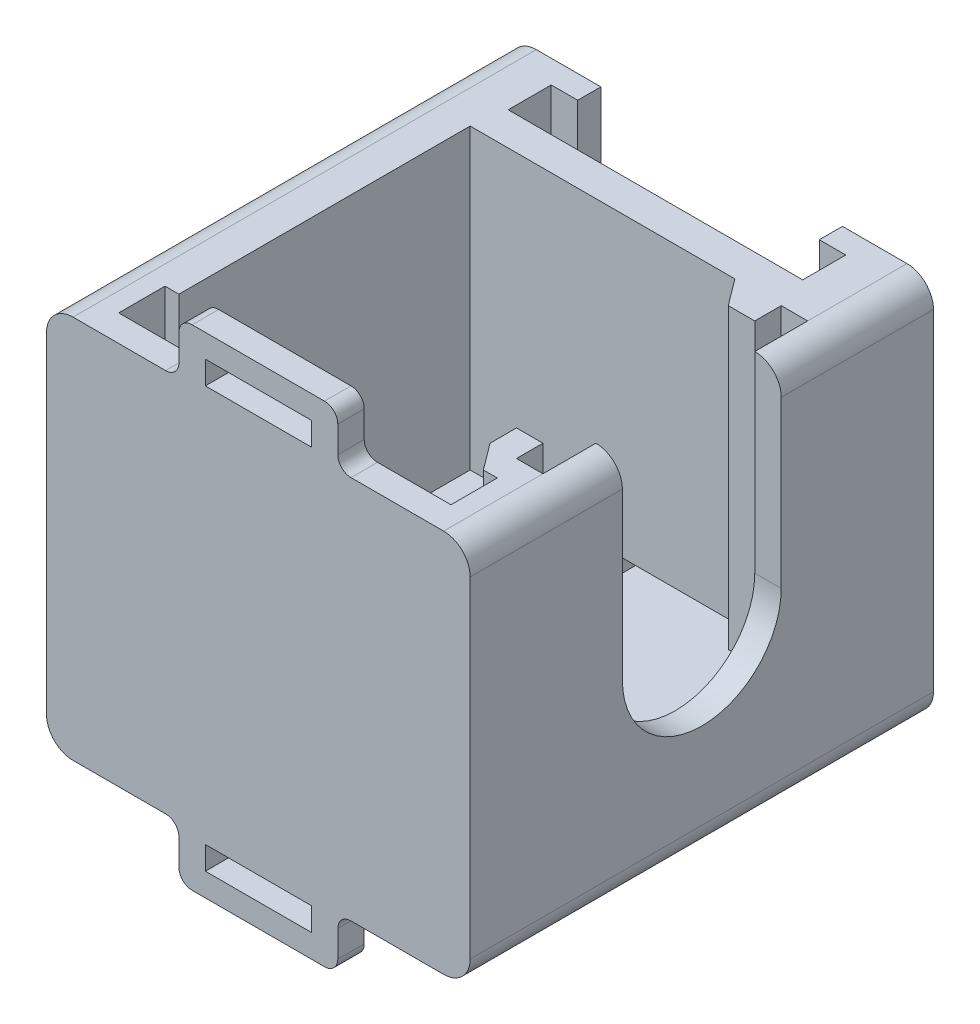
from build123d import *

# Parameters (mm, degrees)
SKETCH1_W                         = 32
SKETCH1_H                         = 29
BOSS_EXTRUDE1_DEPTH               = 35
FILLET1_R                         = 2
SLOT_FOR_COIL_DEPTH               = 1
SLOT_FOR_COIL_DEPTH_BACK          = 30
BOSS_EXTRUDE2_DEPTH               = 6.5
BOSS_EXTRUDE3_DEPTH               = 1.75
SKETCH5_W                         = 2
SKETCH5_H                         = 6.5
SLOT_TO_FEED_IN_WIRE_DEPTH        = 33
SLOT_FO_PCB_DEPTH                 = 22.5
SKETCH7_W                         = 2
SKETCH7_H                         = 33
BOSS_EXTRUDE4_DEPTH               = 2.5
FILLET2_R                         = 6
ROD_MOUNT_SLOT_REACH              = 34
SKETCH14_W                        = 2.5
SKETCH14_H                        = 20
SIDE_CAVITY_FOR_MOUNT_PLATE_DEPTH = 22.5
SKETCH16_W                        = 2
SKETCH16_H                        = 2
SIDE_STOPS_FOR_MOUNT_PLATE_DEPTH  = 22.5
BOSS_EXTRUDE6_DEPTH               = 22.5
SKETCH21_W                        = 12
SKETCH21_H                        = 2
BOSS_EXTRUDE7_DEPTH               = 4
SKETCH23_W                        = 8
SKETCH23_H                        = 1.75
CUT_EXTRUDE7_DEPTH                = 2
FILLET3_R                         = 1
CUT_EXTRUDE8_REACH                = 34
SKETCH26_R                        = 5.25


with BuildPart() as part:
    # Sketch1 → Boss-Extrude1 (new body)
    with BuildSketch(Plane.XY):
        Rectangle(SKETCH1_W, SKETCH1_H)
    extrude(amount=BOSS_EXTRUDE1_DEPTH)

    # Fillet1
    fillet1_edges = [part.edges().sort_by_distance(p)[0] for p in [
        (16, -14.5, 17.5),
        (-16, -14.5, 17.5),
        (-16, 14.5, 17.5),
        (16, 14.5, 17.5),
    ]]
    fillet(fillet1_edges, radius=FILLET1_R)

    # Sketch2 → Slot for Coil (cut, two sides)
    with BuildSketch(Plane.XZ.offset(14.5)) as slot_for_coil_sk:
        Polygon((-9.125, 0), (-9.125, 1.75), (-11.125, 1.75), (-11.125, 5), (11.125, 5), (11.125, 1.75), (9.125, 1.75), (9.125, 0), align=None)
    extrude(amount=SLOT_FOR_COIL_DEPTH, mode=Mode.SUBTRACT)
    extrude(slot_for_coil_sk.sketch, amount=-SLOT_FOR_COIL_DEPTH_BACK, mode=Mode.SUBTRACT)

    # Sketch3 → Boss-Extrude2 (add)
    with BuildSketch(Plane.XZ.offset(14.5)):
        Polygon((-9.125, 0), (-9.125, 1.75), (-11.125, 1.75), (-11.125, 5), (11.125, 5), (11.125, 1.75), (9.125, 1.75), (9.125, 0), align=None)
    extrude(amount=-BOSS_EXTRUDE2_DEPTH)

    # Sketch4 → Boss-Extrude3 (add)
    with BuildSketch(Plane(origin=(0, 0, 1.75), x_dir=(-1, 0, 0), z_dir=(0, 0, -1))):
        with BuildLine():
            Line((-9.125, 7.5), (-9.125, 6.5))
            ThreePointArc((-9.125, 6.5), (-8.875, 7), (-9.125, 7.5))
        make_face()
    boss_extrude3 = extrude(amount=BOSS_EXTRUDE3_DEPTH)

    # Mirror1: Boss-Extrude3 across plane
    add(boss_extrude3.mirror(Plane(origin=(0, 0, 0), x_dir=(0, 0, 1), z_dir=(1, 0, 0))))

    # Sketch5 → slot to feed in wire (cut)
    with BuildSketch(Plane(origin=(0, 0, 0), x_dir=(-1, 0, 0), z_dir=(0, 0, -1))):
        with Locations((0, -11.25)):
            Rectangle(SKETCH5_W, SKETCH5_H)
    extrude(amount=-SLOT_TO_FEED_IN_WIRE_DEPTH, mode=Mode.SUBTRACT)

    # Sketch6 → slot fo PCB (cut)
    with BuildSketch(Plane(origin=(0, 14.5, 0), x_dir=(1, 0, 0), z_dir=(0, 1, 0))):
        Polygon((11.5, -7.5), (-11.5, -7.5), (-11.5, -29.5), (-12.55, -29.5), (-12.55, -33), (12.55, -33), (12.55, -29.5), (11.5, -29.5), align=None)
    extrude(amount=-SLOT_FO_PCB_DEPTH, mode=Mode.SUBTRACT)

    # Sketch7 → Boss-Extrude4 (add)
    with BuildSketch(Plane.XZ.offset(14.5)):
        with Locations((0, 16.5)):
            Rectangle(SKETCH7_W, SKETCH7_H)
    extrude(amount=-BOSS_EXTRUDE4_DEPTH)

    # Fillet2
    fillet2_edges = [part.edges().sort_by_distance(p)[0] for p in [
        (0, -12, 33),
    ]]
    fillet(fillet2_edges, radius=FILLET2_R)

    # Sketch11 → Rod Mount Slot (cut, up to next)
    with BuildSketch(Plane(origin=(16, 0, 44), x_dir=(0, 0, -1), z_dir=(1, 0, 0)), mode=Mode.PRIVATE) as rod_mount_slot_sk1:
        with BuildLine():
            Line((32.5, 25), (32.5, 0))
            ThreePointArc((32.5, 0), (26.5, -6), (20.5, 0))
            Line((20.5, 0), (20.5, 25))
            ThreePointArc((20.5, 25), (26.5, 31), (32.5, 25))
        make_face()
    rod_mount_slot_tool1 = extrude(rod_mount_slot_sk1.sketch, amount=-ROD_MOUNT_SLOT_REACH, mode=Mode.PRIVATE) & part.part
    add(rod_mount_slot_tool1.solids().sort_by_distance((16, 12.5, 17.5))[0], mode=Mode.SUBTRACT)

    # Sketch14 → Side cavity for mount plate (cut)
    with BuildSketch(Plane(origin=(0, 14.5, 0), x_dir=(1, 0, 0), z_dir=(0, 1, 0))):
        with Locations((12.75, -17.5)):
            Rectangle(SKETCH14_W, SKETCH14_H)
    extrude(amount=-SIDE_CAVITY_FOR_MOUNT_PLATE_DEPTH, mode=Mode.SUBTRACT)

    # Sketch16 → Side stops for mount plate (add)
    with BuildSketch(Plane(origin=(0, 14.5, 0), x_dir=(1, 0, 0), z_dir=(0, 1, 0))):
        with Locations((11, -8.5)):
            Rectangle(SKETCH16_W, SKETCH16_H)
        with Locations((11, -26.5)):
            Rectangle(SKETCH16_W, SKETCH16_H)
    extrude(amount=-SIDE_STOPS_FOR_MOUNT_PLATE_DEPTH)

    # Sketch20 → Boss-Extrude6 (add)
    with BuildSketch(Plane(origin=(0, 14.5, 0), x_dir=(1, 0, 0), z_dir=(0, 1, 0))):
        Polygon((11.5, -29.5), (10, -27.5), (11.5, -27.5), align=None)
        Polygon((10, -9.5), (8.5, -7.5), (10, -7.5), align=None)
    extrude(amount=-BOSS_EXTRUDE6_DEPTH)

    # Sketch21 → Boss-Extrude7 (add)
    with BuildSketch(Plane(origin=(0, 14.5, 0), x_dir=(-1, 0, 0), z_dir=(0, 1, 0))):
        with Locations((0, 34)):
            Rectangle(SKETCH21_W, SKETCH21_H)
    boss_extrude7 = extrude(amount=BOSS_EXTRUDE7_DEPTH)

    # Sketch23 → Cut-Extrude7 (cut)
    with BuildSketch(Plane.XY.offset(35)):
        with Locations((0, 15.875)):
            Rectangle(SKETCH23_W, SKETCH23_H)
    cut_extrude7 = extrude(amount=-CUT_EXTRUDE7_DEPTH, mode=Mode.SUBTRACT)

    # Mirror3: Boss-Extrude7, Cut-Extrude7 across plane
    add(boss_extrude7.mirror(Plane.ZX))
    add(cut_extrude7.mirror(Plane.ZX), mode=Mode.SUBTRACT)

    # Fillet3
    fillet3_edges = [part.edges().sort_by_distance(p)[0] for p in [
        (6, 14.5, 34),
        (-6, 14.5, 34),
        (6, 18.5, 34),
        (-6, 18.5, 34),
        (6, -18.5, 34),
        (-6, -18.5, 34),
        (6, -14.5, 34),
        (-6, -14.5, 34),
    ]]
    fillet(fillet3_edges, radius=FILLET3_R)

    # Sketch26 → Cut-Extrude8 (cut, up to next)
    with BuildSketch(Plane(origin=(-16, 0, 0), x_dir=(0, 0, -1), z_dir=(1, 0, 0)), mode=Mode.PRIVATE) as cut_extrude8_sk1:
        with Locations((-23.015, -2.89)):
            Circle(SKETCH26_R)
    cut_extrude8_tool1 = extrude(cut_extrude8_sk1.sketch, amount=CUT_EXTRUDE8_REACH, mode=Mode.PRIVATE) & part.part
    add(cut_extrude8_tool1.solids().sort_by_distance((-16, -2.89, 23.015))[0], mode=Mode.SUBTRACT)


solid = part.part
